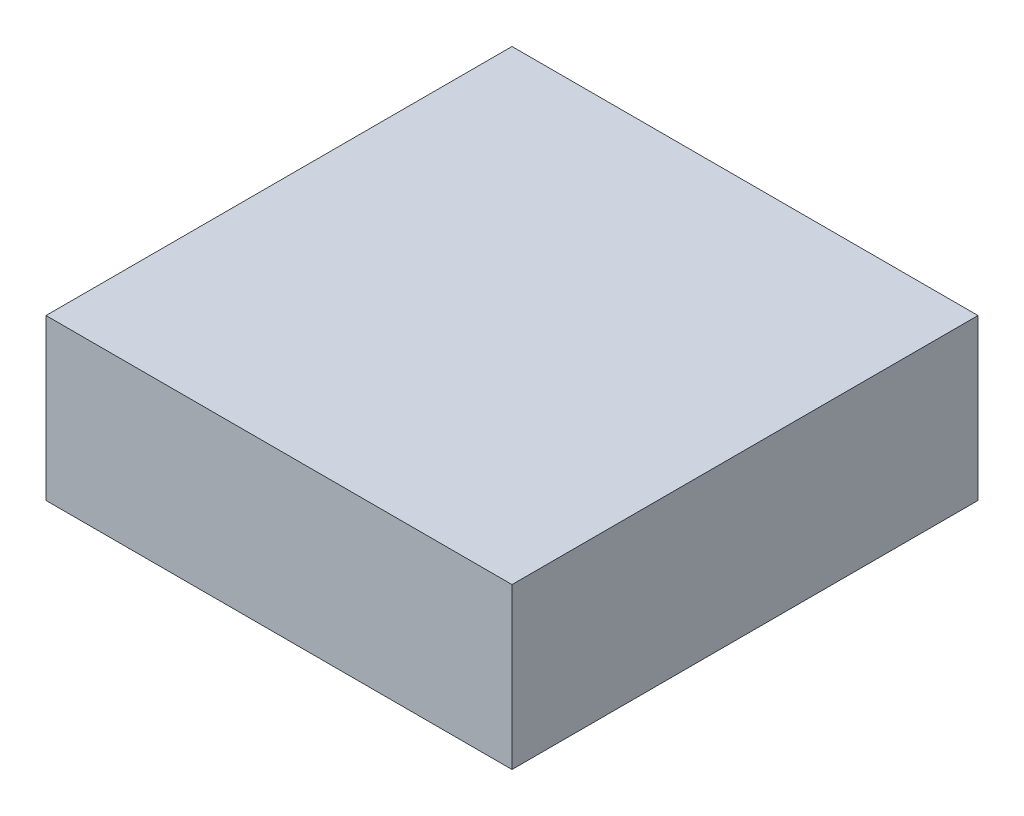
from build123d import *

# Parameters (mm, degrees)
SALIENTE_EXTRUIR1_DEPTH = 32
CORTAR_EXTRUIR1_DEPTH   = 33
CROQUIS4_R              = 1
SALIENTE_EXTRUIR2_DEPTH = 0.005


with BuildPart() as part:
    # Croquis1 → Saliente-Extruir1 (new body)
    with BuildSketch(Plane.XY):
        Polygon((-51.959662641, 14.148169014), (-51.959662641, 3.148169014), (-35.959662641, -4.290206314), (-19.959662641, 3.148169014), (-19.959662641, 14.148169014), align=None)
    extrude(amount=SALIENTE_EXTRUIR1_DEPTH)

    # Croquis2 → Cortar-Extruir1 (cut)
    with BuildSketch(Plane(origin=(-19.959662641, 0, 0), x_dir=(0, 0, -1), z_dir=(1, 0, 0))):
        Polygon((0, -4.290206314), (-16, -4.290206314), (0, 3.148169014), align=None)
        Polygon((-32, -4.290206314), (-32, 3.148169014), (-16, -4.290206314), align=None)
    extrude(amount=-CORTAR_EXTRUIR1_DEPTH, mode=Mode.SUBTRACT)

    # Croquis4 → Saliente-Extruir2 (add)
    with BuildSketch(Plane(origin=(-4.750700642, 10.218791996, 0), x_dir=(-0.906796627, -0.421568354, 0), z_dir=(0.421568354, -0.906796627, 0))):
        with Locations((20.772186335, -16)):
            Circle(CROQUIS4_R)
    extrude(amount=SALIENTE_EXTRUIR2_DEPTH)


solid = part.part
